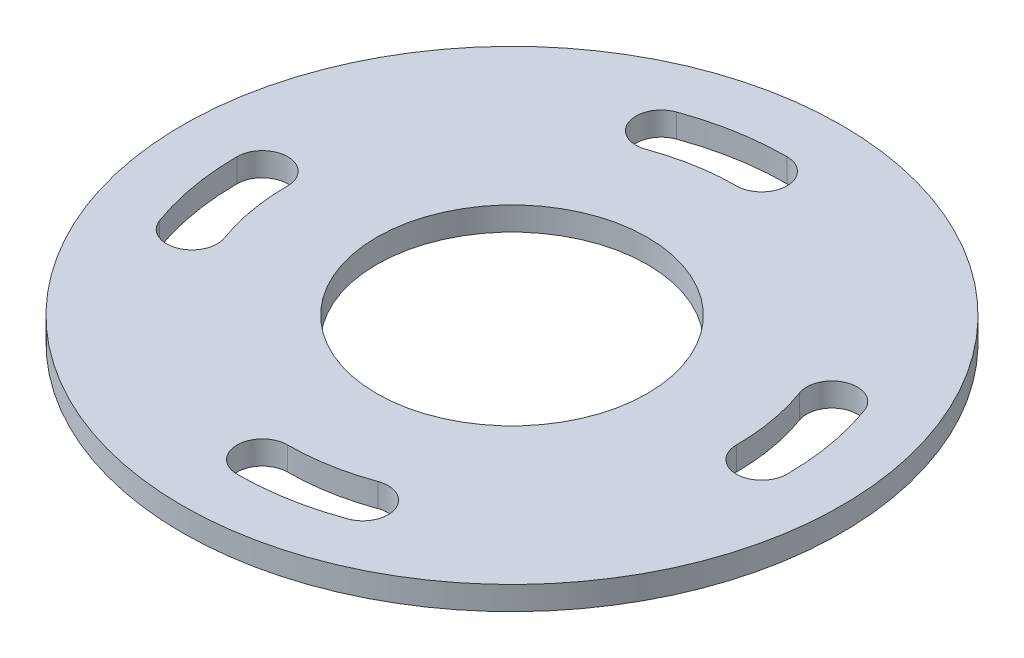
from build123d import *

# Parameters (mm, degrees)
SKETCH1_R           = 28
SKETCH1_R_2         = 11.5
BOSS_EXTRUDE1_DEPTH = 2
CUT_EXTRUDE1_DEPTH  = 3
CIRPATTERN1_COUNT   = 4


with BuildPart() as part:
    # Sketch1 → Boss-Extrude1 (new body)
    with BuildSketch(Plane(origin=(0, 0, 0), x_dir=(1, 0, 0), z_dir=(0, 1, 0))):
        Circle(SKETCH1_R)
        Circle(SKETCH1_R_2, mode=Mode.SUBTRACT)
    extrude(amount=BOSS_EXTRUDE1_DEPTH)

    # Sketch2 → Cut-Extrude1 (cut, through all)
    with BuildSketch(Plane(origin=(0, 2, 0), x_dir=(1, 0, 0), z_dir=(0, 1, 0))):
        with BuildLine():
            ThreePointArc((21.954229866, 7.990686188), (19.198547424, 9.275682014), (17.913551597, 6.519999571))
            ThreePointArc((17.913551597, 6.519999571), (18.773590541, 3.310290537), (19.063203436, 0))
            ThreePointArc((19.063203436, 0), (21.213203436, -2.15), (23.363203436, 0))
            ThreePointArc((23.363203436, 0), (23.008263879, 4.056977701), (21.954229866, 7.990686188))
        make_face()
    cut_extrude1 = extrude(amount=-CUT_EXTRUDE1_DEPTH, mode=Mode.SUBTRACT)

    # CirPattern1: Cut-Extrude1 ×4 about axis
    cirpattern1_axis = Axis((0, 0, 0), (0, 1, 0))
    for i in range(1, CIRPATTERN1_COUNT):
        add(cut_extrude1.rotate(cirpattern1_axis, i * 360 / CIRPATTERN1_COUNT), mode=Mode.SUBTRACT)


solid = part.part
